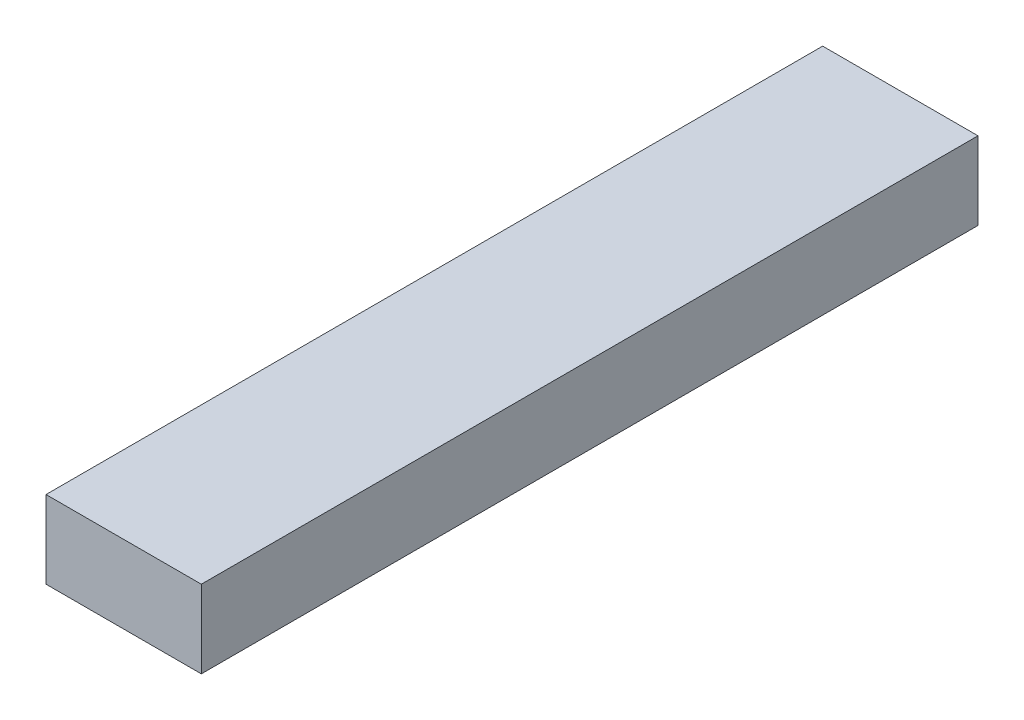
from build123d import *

# Parameters (mm, degrees)
SKETCH1_W           = 20
SKETCH1_H           = 100
BOSS_EXTRUDE1_DEPTH = 10


with BuildPart() as part:
    # Sketch1 → Boss-Extrude1 (new body)
    with BuildSketch(Plane(origin=(0, 0, 0), x_dir=(1, 0, 0), z_dir=(0, 1, 0))):
        Rectangle(SKETCH1_W, SKETCH1_H)
    extrude(amount=BOSS_EXTRUDE1_DEPTH)


solid = part.part
